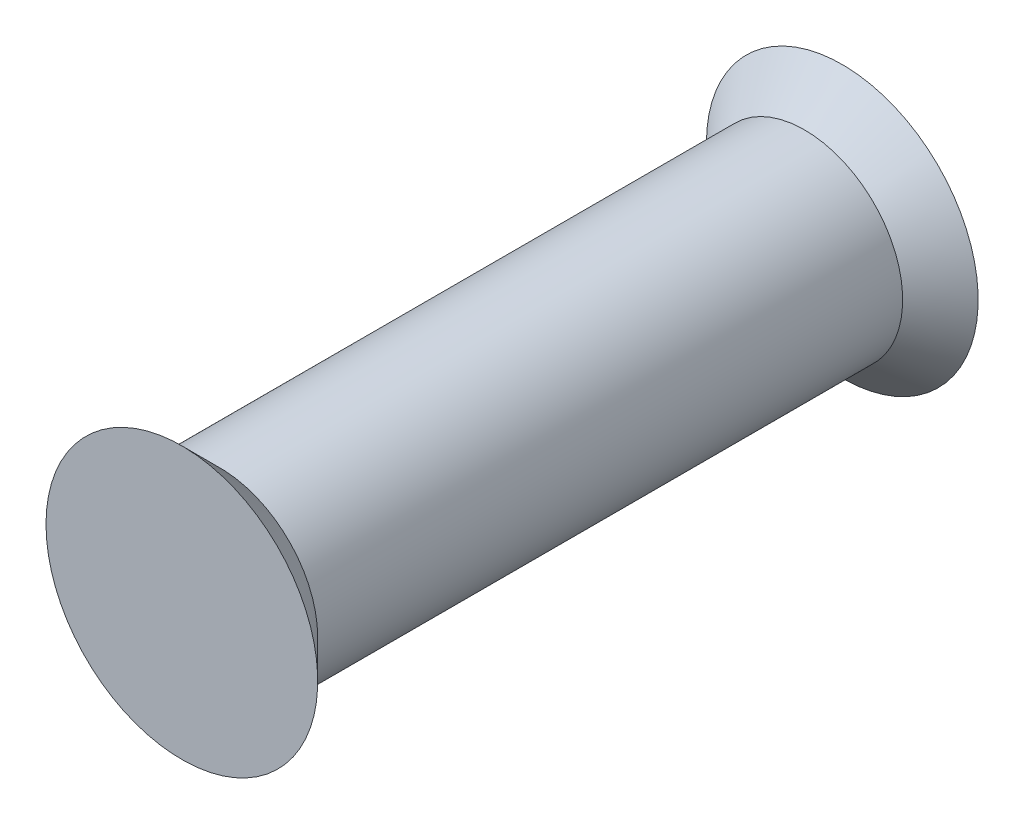
from build123d import *

# Parameters (mm, degrees)
SKETCH1_W = 2.6
SKETCH1_H = 17.5


with BuildPart() as part:
    # Sketch1 → Revolve1 (revolve)
    with BuildSketch(Plane(origin=(0, 0, 0), x_dir=(1, 0, 0), z_dir=(0, 1, 0))):
        with Locations((-1.3, 0)):
            Rectangle(SKETCH1_W, SKETCH1_H)
    revolve(axis=Axis((0, 0, -13.659521107), (0, 0, 1)))

    # Sketch2 → Revolve2 (revolve)
    with BuildSketch(Plane(origin=(0, 0, 0), x_dir=(1, 0, 0), z_dir=(0, 1, 0))):
        Polygon((-2.6, -7.75), (-3.6, -8.75), (-2.6, -8.75), align=None)
    revolve2 = revolve(axis=Axis((0, 0, -14.722770412), (0, 0, 1)))

    # Mirror1: Revolve2 across plane
    add(revolve2.mirror(Plane.XY))


solid = part.part
